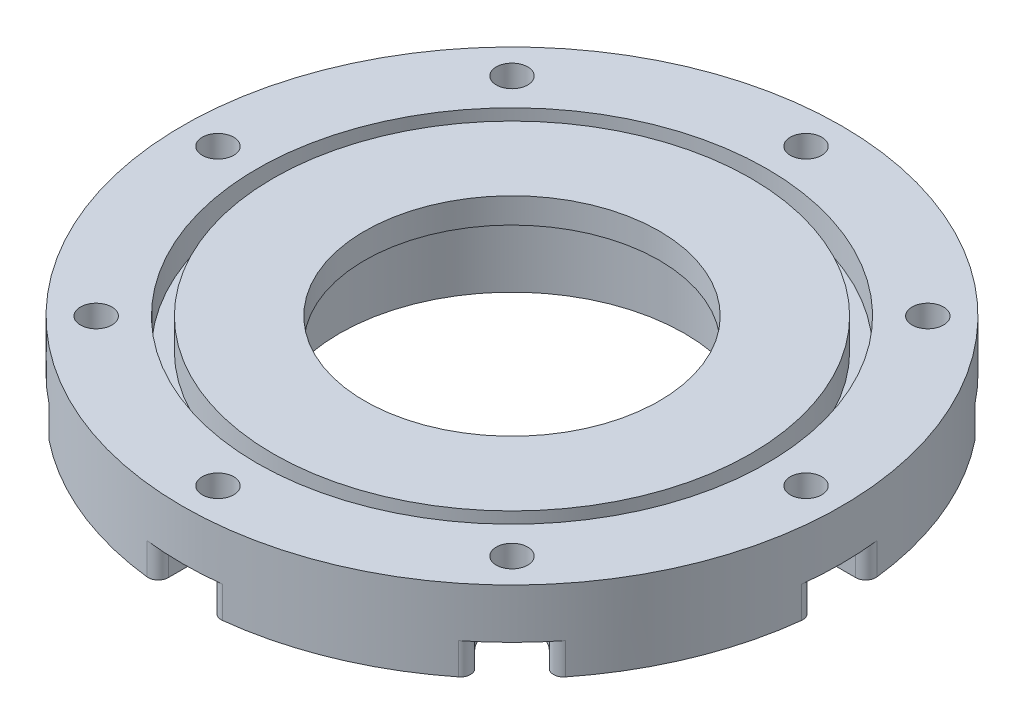
from build123d import *

# Parameters (mm, degrees)
ESQUISSE2_R             = 3.1
ENL_V_MAT_EXTRU_1_DEPTH = 21
ESQUISSE4_OUTSIDE_W     = 168.986
ESQUISSE4_OUTSIDE_H     = 168.986
ESQUISSE4_OUTSIDE_R     = 42.05
ENL_V_MAT_EXTRU_3_DEPTH = 4
ESQUISSE3_R             = 5.1
ENL_V_MAT_EXTRU_2_DEPTH = 6.2
ENL_V_MAT_EXTRU_4_DEPTH = 6.2
CONG_2_R                = 2


with BuildPart() as part:
    # Esquisse1 → Révolution1 (revolve)
    with BuildSketch(Plane.XY):
        Polygon((-34.05, 0), (-34.05, 15), (-29.05, 15), (-29.05, 20), (-47.1, 20), (-47.1, 14), (-50.3, 14), (-50.3, 20), (-65, 20), (-65, 0), align=None)
    revolve(axis=Axis((0, 0, 0), (0, 1, 0)))

    # Esquisse2 → Enlèv. mat.-Extru.1 (cut, through all)
    with BuildSketch(Plane.XZ):
        with Locations((0, 58)):
            Circle(ESQUISSE2_R)
        with Locations((41.012193309, 41.012193309)):
            Circle(ESQUISSE2_R)
        with Locations((58, 0)):
            Circle(ESQUISSE2_R)
        with Locations((41.012193309, -41.012193309)):
            Circle(ESQUISSE2_R)
        with Locations((0, -58)):
            Circle(ESQUISSE2_R)
        with Locations((-41.012193309, -41.012193309)):
            Circle(ESQUISSE2_R)
        with Locations((-58, 0)):
            Circle(ESQUISSE2_R)
        with Locations((-41.012193309, 41.012193309)):
            Circle(ESQUISSE2_R)
    extrude(amount=-ENL_V_MAT_EXTRU_1_DEPTH, mode=Mode.SUBTRACT)

    # Esquisse4 outside → Enlèv. mat.-Extru.3 (cut)
    with BuildSketch(Plane.XZ):
        Rectangle(ESQUISSE4_OUTSIDE_W, ESQUISSE4_OUTSIDE_H)
        Circle(ESQUISSE4_OUTSIDE_R, mode=Mode.SUBTRACT)
    extrude(amount=-ENL_V_MAT_EXTRU_3_DEPTH, mode=Mode.SUBTRACT)

    # Esquisse3 → Enlèv. mat.-Extru.2 (cut)
    with BuildSketch(Plane.XZ.offset(-4)):
        with Locations((0, 58)):
            Circle(ESQUISSE3_R)
        with Locations((41.012193309, 41.012193309)):
            Circle(ESQUISSE3_R)
        with Locations((58, 0)):
            Circle(ESQUISSE3_R)
        with Locations((41.012193309, -41.012193309)):
            Circle(ESQUISSE3_R)
        with Locations((0, -58)):
            Circle(ESQUISSE3_R)
        with Locations((-41.012193309, -41.012193309)):
            Circle(ESQUISSE3_R)
        with Locations((-58, 0)):
            Circle(ESQUISSE3_R)
        with Locations((-41.012193309, 41.012193309)):
            Circle(ESQUISSE3_R)
    extrude(amount=-ENL_V_MAT_EXTRU_2_DEPTH, mode=Mode.SUBTRACT)

    # Esquisse5 → Enlèv. mat.-Extru.4 (cut)
    with BuildSketch(Plane.XZ.offset(-4)):
        with BuildLine():
            Line((5.2, -58), (5.2, -69.173010208))
            ThreePointArc((5.2, -69.173010208), (0, -74.373010208), (-5.2, -69.173010208))
            Line((-5.2, -69.173010208), (-5.2, -58))
            ThreePointArc((-5.2, -58), (0, -52.8), (5.2, -58))
        make_face()
        with BuildLine():
            Line((-37.335238047, -44.689148571), (-45.235749331, -52.589659855))
            ThreePointArc((-45.235749331, -52.589659855), (-52.589659855, -52.589659855), (-52.589659855, -45.235749331))
            Line((-52.589659855, -45.235749331), (-44.689148571, -37.335238047))
            ThreePointArc((-44.689148571, -37.335238047), (-37.335238047, -37.335238047), (-37.335238047, -44.689148571))
        make_face()
        with BuildLine():
            Line((-58, -5.2), (-69.173010208, -5.2))
            ThreePointArc((-69.173010208, -5.2), (-74.373010208, 0), (-69.173010208, 5.2))
            Line((-69.173010208, 5.2), (-58, 5.2))
            ThreePointArc((-58, 5.2), (-52.8, 0), (-58, -5.2))
        make_face()
        with BuildLine():
            Line((-44.689148571, 37.335238047), (-52.589659855, 45.235749331))
            ThreePointArc((-52.589659855, 45.235749331), (-52.589659855, 52.589659855), (-45.235749331, 52.589659855))
            Line((-45.235749331, 52.589659855), (-37.335238047, 44.689148571))
            ThreePointArc((-37.335238047, 44.689148571), (-37.335238047, 37.335238047), (-44.689148571, 37.335238047))
        make_face()
        with BuildLine():
            Line((-5.2, 58), (-5.2, 69.173010208))
            ThreePointArc((-5.2, 69.173010208), (0, 74.373010208), (5.2, 69.173010208))
            Line((5.2, 69.173010208), (5.2, 58))
            ThreePointArc((5.2, 58), (0, 52.8), (-5.2, 58))
        make_face()
        with BuildLine():
            Line((37.335238047, 44.689148571), (45.235749331, 52.589659855))
            ThreePointArc((45.235749331, 52.589659855), (52.589659855, 52.589659855), (52.589659855, 45.235749331))
            Line((52.589659855, 45.235749331), (44.689148571, 37.335238047))
            ThreePointArc((44.689148571, 37.335238047), (37.335238047, 37.335238047), (37.335238047, 44.689148571))
        make_face()
        with BuildLine():
            Line((58, 5.2), (69.173010208, 5.2))
            ThreePointArc((69.173010208, 5.2), (74.373010208, 0), (69.173010208, -5.2))
            Line((69.173010208, -5.2), (58, -5.2))
            ThreePointArc((58, -5.2), (52.8, 0), (58, 5.2))
        make_face()
        with BuildLine():
            Line((44.689148571, -37.335238047), (52.589659855, -45.235749331))
            ThreePointArc((52.589659855, -45.235749331), (52.589659855, -52.589659855), (45.235749331, -52.589659855))
            Line((45.235749331, -52.589659855), (37.335238047, -44.689148571))
            ThreePointArc((37.335238047, -44.689148571), (37.335238047, -37.335238047), (44.689148571, -37.335238047))
        make_face()
    extrude(amount=-ENL_V_MAT_EXTRU_4_DEPTH, mode=Mode.SUBTRACT)

    # Congé2
    cong_2_edges = [part.edges().sort_by_distance(p)[0] for p in [
        (49.491581748, 7.1, -42.137671223),
        (42.137671223, 7.1, -49.491581748),
        (64.791666131, 7.1, 5.2),
        (64.791666131, 7.1, -5.2),
        (42.137671223, 7.1, 49.491581748),
        (49.491581748, 7.1, 42.137671223),
        (-5.2, 7.1, 64.791666131),
        (5.2, 7.1, 64.791666131),
        (-49.491581748, 7.1, 42.137671223),
        (-42.137671223, 7.1, 49.491581748),
        (-64.791666131, 7.1, -5.2),
        (-64.791666131, 7.1, 5.2),
        (-42.137671223, 7.1, -49.491581748),
        (-49.491581748, 7.1, -42.137671223),
        (5.2, 7.1, -64.791666131),
        (-5.2, 7.1, -64.791666131),
    ]]
    fillet(cong_2_edges, radius=CONG_2_R)


solid = part.part
